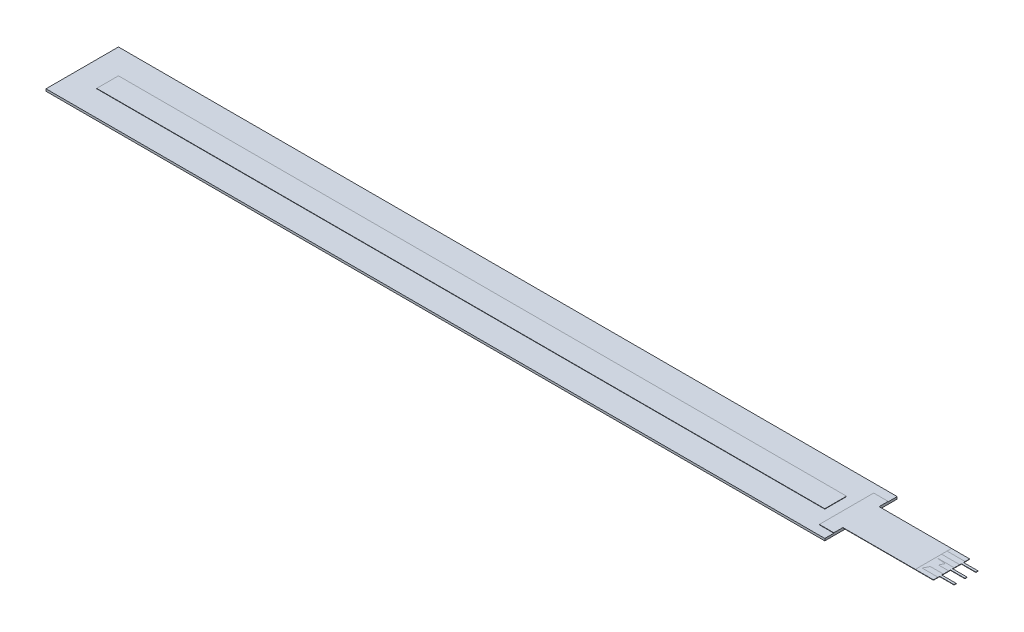
from build123d import *

# Parameters (mm, degrees)
MAIN_BODY_W           = 215
MAIN_BODY_H           = 20
BOSS_EXTRUDE1_DEPTH   = 0.6
SKETCH2_W             = 201
SKETCH2_H             = 6
BOSS_EXTRUDE2_DEPTH   = 0.1
BOSS_EXTRUDE3_DEPTH   = 0.1
SKETCH4_W             = 10
SKETCH4_H             = 0.1
BOSS_EXTRUDE4_DEPTH   = 5
BOSS_EXTRUDE5_DEPTH   = 0.1
BOSS_EXTRUDE5_2_DEPTH = 0.1
BOSS_EXTRUDE5_3_DEPTH = 0.1


with BuildPart() as part:
    # main_body → Boss-Extrude1 (new body)
    with BuildSketch(Plane(origin=(0, 0, 0), x_dir=(1, 0, 0), z_dir=(0, 1, 0))):
        Rectangle(MAIN_BODY_W, MAIN_BODY_H)
    extrude(amount=BOSS_EXTRUDE1_DEPTH)

    # Sketch2 → Boss-Extrude2 (add)
    with BuildSketch(Plane(origin=(0, 0.6, 0), x_dir=(1, 0, 0), z_dir=(0, 1, 0))):
        Rectangle(SKETCH2_W, SKETCH2_H)
    extrude(amount=BOSS_EXTRUDE2_DEPTH)

    # Sketch3 → Boss-Extrude3 (add)
    with BuildSketch(Plane(origin=(0, 0.6, 0), x_dir=(1, 0, 0), z_dir=(0, 1, 0))):
        Polygon((107.5, 5), (127.5, 5), (127.5, -5), (107.5, -5), (107.5, -7.5), (103.5, -7.5), (103.5, 7.5), (107.5, 7.5), align=None)
    extrude(amount=BOSS_EXTRUDE3_DEPTH)


with BuildPart() as body_2:
    # Sketch4 → Boss-Extrude4 (new body)
    with BuildSketch(Plane(origin=(127.5, 0, 0), x_dir=(0, 0, -1), z_dir=(1, 0, 0))):
        with Locations((0, 0.65)):
            Rectangle(SKETCH4_W, SKETCH4_H)
    extrude(amount=BOSS_EXTRUDE4_DEPTH)


with BuildPart() as body_3:
    # Sketch5 → Boss-Extrude5 (new body)
    with BuildSketch(Plane(origin=(0, 0.7, 0), x_dir=(1, 0, 0), z_dir=(0, 1, 0))):
        Polygon((127.5, 3.75), (132.5, 3.75), (132.5, 3.3), (136.5, 3.3), (136.5, 2.7), (132.5, 2.7), (132.5, 2.25), (127.5, 2.25), align=None)
    extrude(amount=-BOSS_EXTRUDE5_DEPTH)


with BuildPart() as body_4:
    # Sketch5 → Boss-Extrude5 2 (new body)
    with BuildSketch(Plane(origin=(0, 0.7, 0), x_dir=(1, 0, 0), z_dir=(0, 1, 0))):
        Polygon((127.5, 0.75), (132.5, 0.75), (132.5, 0.3), (136.5, 0.3), (136.5, -0.3), (132.5, -0.3), (132.5, -0.75), (127.5, -0.75), align=None)
    extrude(amount=-BOSS_EXTRUDE5_2_DEPTH)


with BuildPart() as body_5:
    # Sketch5 → Boss-Extrude5 3 (new body)
    with BuildSketch(Plane(origin=(0, 0.7, 0), x_dir=(1, 0, 0), z_dir=(0, 1, 0))):
        Polygon((127.5, -2.25), (132.5, -2.25), (132.5, -2.7), (136.5, -2.7), (136.5, -3.3), (132.5, -3.3), (132.5, -3.75), (127.5, -3.75), align=None)
    extrude(amount=-BOSS_EXTRUDE5_3_DEPTH)


solid = Compound([part.part, body_2.part, body_3.part, body_4.part, body_5.part])
